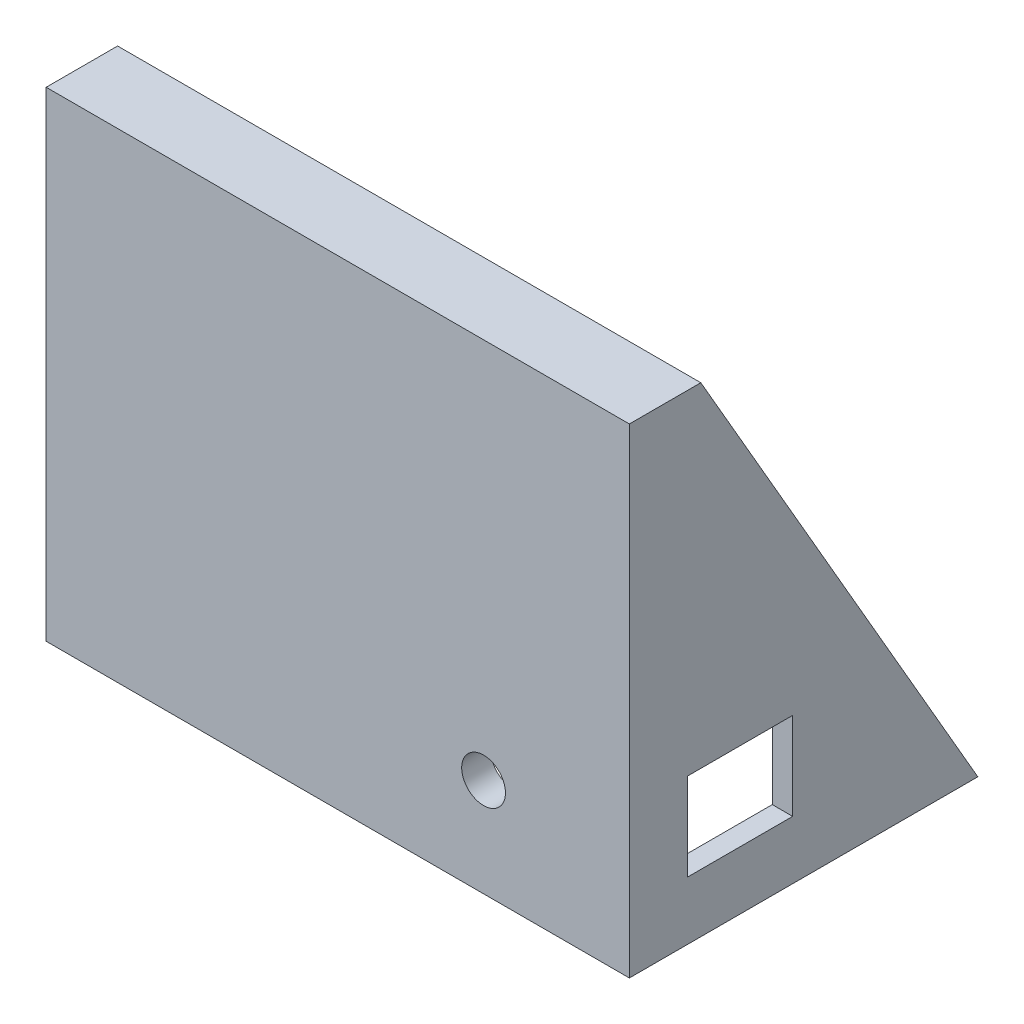
from build123d import *

# Parameters (mm, degrees)
BOSS_EXTRUDE1_DEPTH      = 200
SHELL1_T                 = -10
SHELL1_THICKNESS_2_DEPTH = 3
SHELL1_THICKNESS_3_DEPTH = 3
SKETCH4_R                = 2.5
CUT_EXTRUDE2_DEPTH       = 5
SKETCH5_W                = 36
SKETCH5_H                = 30
CUT_EXTRUDE3_DEPTH       = 20
SKETCH6_R                = 7.5
CUT_EXTRUDE4_DEPTH       = 20


with BuildPart() as part:
    # Sketch2 → Boss-Extrude1 (new body)
    with BuildSketch(Plane(origin=(0, 0, 0), x_dir=(0, 0, -1), z_dir=(1, 0, 0))):
        Polygon((0, 60.789473684), (24.5, 60.789473684), (119.5, -103.755353035), (0, -103.755353035), align=None)
    extrude(amount=BOSS_EXTRUDE1_DEPTH)

    # Shell1
    shell1_openings = [part.faces().sort_by_distance(p)[0] for p in [
        (100, -103.755353035, -59.75),
    ]]
    offset(amount=SHELL1_T, openings=shell1_openings, kind=Kind.INTERSECTION)

    # Shell1 thickness 2 face (on inner face of the shell) → Shell1 thickness 2 (cut)
    with BuildSketch(Plane(origin=(190, -48.02643305, -42.888943831), x_dir=(0, 0, 1), z_dir=(1, 0, 0))):
        Polygon((32.888943831, -98.815906734), (24.162446523, -98.815906734), (-65.064050785, 55.728919985), (32.888943831, 55.728919985), align=None)
    extrude(amount=SHELL1_THICKNESS_2_DEPTH, mode=Mode.SUBTRACT)

    # Shell1 thickness 3 face (on inner face of the shell) → Shell1 thickness 3 (cut)
    with BuildSketch(Plane(origin=(10, -48.02643305, -42.888943831), x_dir=(0, 0, -1), z_dir=(-1, 0, 0))):
        Polygon((-24.162446523, -98.815906734), (-32.888943831, -98.815906734), (-32.888943831, 55.728919985), (65.064050785, 55.728919985), align=None)
    extrude(amount=SHELL1_THICKNESS_3_DEPTH, mode=Mode.SUBTRACT)

    # Sketch4 → Cut-Extrude2 (cut)
    with BuildSketch(Plane(origin=(0, 25.806179617, -44.697614247), x_dir=(-1, 0, 0), z_dir=(0, 0.499999999999998, -0.8660254037844397))):
        with Locations(Location((-185, 0.395228493, 0), (0, 0, 90))):
            Circle(SKETCH4_R)
        with Locations(Location((-185, -109.604771507, 0), (0, 0, 90))):
            Circle(SKETCH4_R)
        with Locations(Location((-155, -139.604771507, 0), (0, 0, 90))):
            Circle(SKETCH4_R)
        with Locations(Location((-45, -139.604771507, 0), (0, 0, 90))):
            Circle(SKETCH4_R)
        with Locations(Location((-15, -109.604771507, 0), (0, 0, 90))):
            Circle(SKETCH4_R)
        with Locations(Location((-15, 0.395228493, 0), (0, 0, 90))):
            Circle(SKETCH4_R)
        with Locations(Location((-45, 30.395228493, 0), (0, 0, 90))):
            Circle(SKETCH4_R)
        with Locations(Location((-155, 30.395228493, 0), (0, 0, 90))):
            Circle(SKETCH4_R)
    extrude(amount=-CUT_EXTRUDE2_DEPTH, mode=Mode.SUBTRACT)

    # Sketch5 → Cut-Extrude3 (cut)
    with BuildSketch(Plane(origin=(200, 0, 0), x_dir=(0, 0, -1), z_dir=(1, 0, 0))):
        with Locations((38, -68.755353035)):
            Rectangle(SKETCH5_W, SKETCH5_H)
    extrude(amount=-CUT_EXTRUDE3_DEPTH, mode=Mode.SUBTRACT)

    # Sketch6 → Cut-Extrude4 (cut)
    with BuildSketch(Plane.XY):
        with Locations((150, -70.035876083)):
            Circle(SKETCH6_R)
    extrude(amount=-CUT_EXTRUDE4_DEPTH, mode=Mode.SUBTRACT)


solid = part.part
